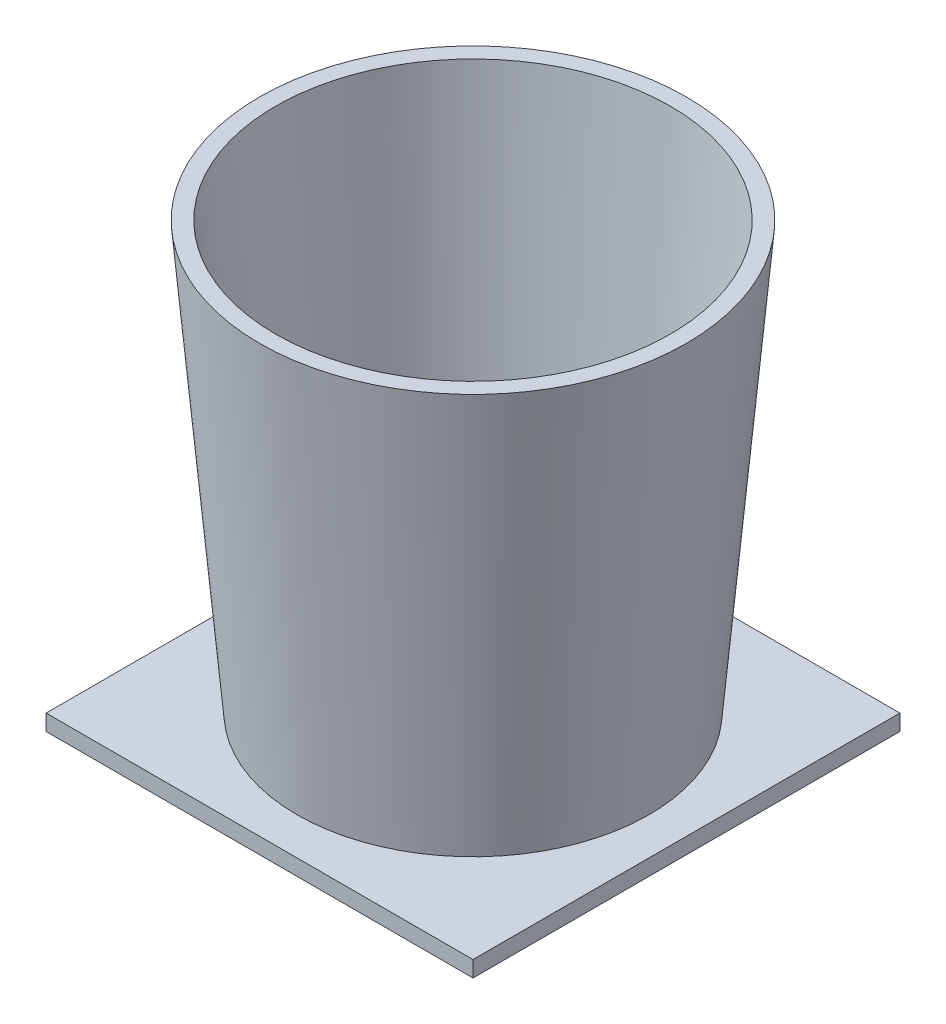
from build123d import *

# Parameters (mm, degrees)
ESQUISSE3_W        = 80
ESQUISSE3_H        = 80
BOSS_EXTRU_1_DEPTH = 3


with BuildPart() as part:
    # Esquisse3 → Boss.-Extru.1 (new body)
    with BuildSketch(Plane(origin=(0, 0, 0), x_dir=(1, 0, 0), z_dir=(0, 1, 0))):
        Rectangle(ESQUISSE3_W, ESQUISSE3_H)
    extrude(amount=BOSS_EXTRU_1_DEPTH)

    # Esquisse4 → Révolution1 (revolve)
    with BuildSketch(Plane.XY):
        Polygon((33.000906918, 3), (40, 83), (37, 83), (30.000906918, 3), align=None)
    revolve(axis=Axis((0, 5.327964133, 0), (0, 1, 0)))


solid = part.part
